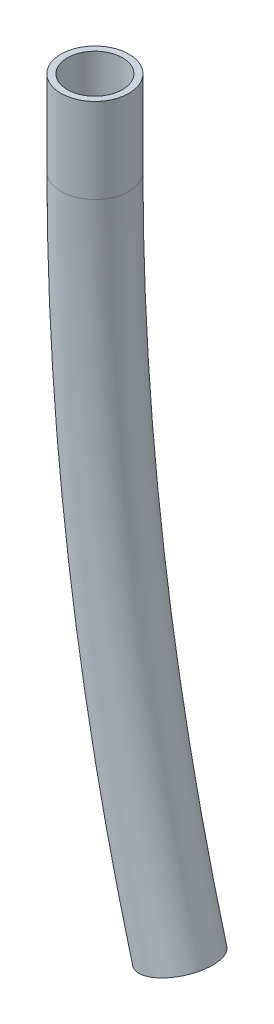
from build123d import *

# Parameters (mm, degrees)
WYCI_GNI_CIE_PO_CIE_CE_CIENKA_CIAN_2_R   = 8
WYCI_GNI_CIE_PO_CIE_CE_CIENKA_CIAN_2_R_2 = 6.5


with BuildPart() as part:
    # Wyci_gni_cie po _cie_ce-Cienka _cianka1: sweep along a path in Szkic1
    with BuildLine(Plane.XY) as wyci_gni_cie_po_cie_ce_cienka_cianka1_path:
        Line((0, 0), (0, -20))
        ThreePointArc((0, -20), (5.022026859, -95.663729752), (20, -170))
    # Wyci_gni_cie po _cie_ce-Cienka _cian 2 (on start of the path) → Wyci_gni_cie po _cie_ce-Cienka _cianka1 (sweep)
    with BuildSketch(Plane(origin=(0, 0, 0), x_dir=(0, 0, -1), z_dir=(0, -1, 0))):
        Circle(WYCI_GNI_CIE_PO_CIE_CE_CIENKA_CIAN_2_R)
        Circle(WYCI_GNI_CIE_PO_CIE_CE_CIENKA_CIAN_2_R_2, mode=Mode.SUBTRACT)
    sweep(path=wyci_gni_cie_po_cie_ce_cienka_cianka1_path.line)


solid = part.part
